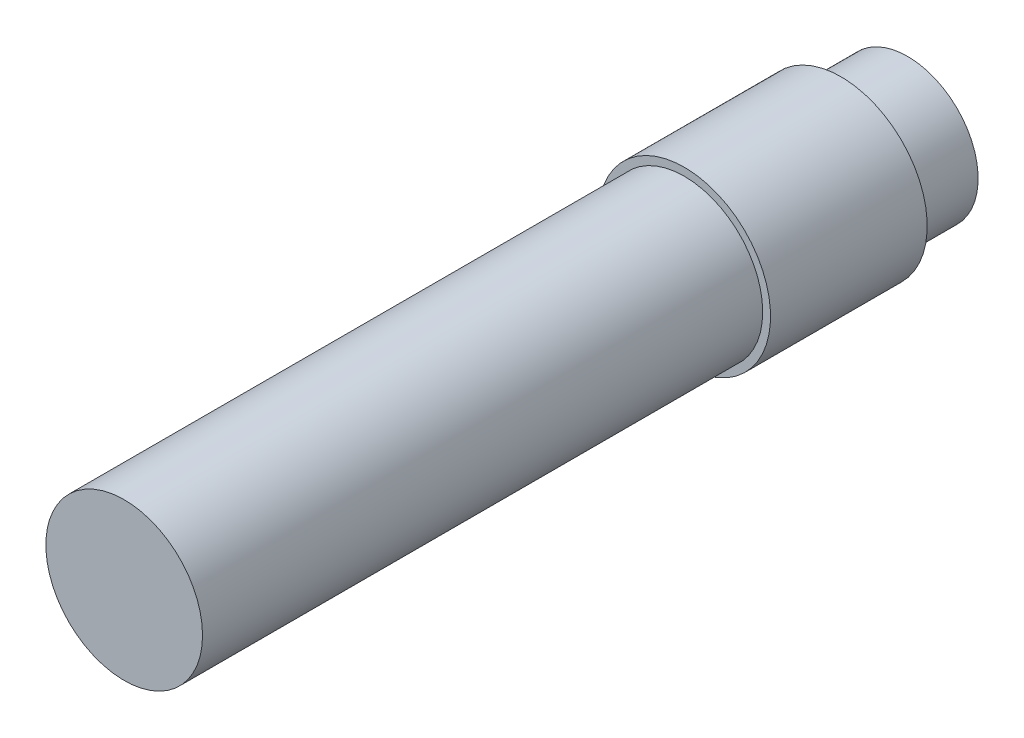
from build123d import *

# Parameters (mm, degrees)
SKETCH_1_R          = 11
EXTRUDE_1_DEPTH     = 100
SKETCH_2_R          = 11
SKETCH_2_R_2        = 9
CUT_EXTRUDE_1_DEPTH = 8.5
SKETCH_3_R          = 11
SKETCH_3_R_2        = 10
CUT_EXTRUDE_2_DEPTH = 71.5


with BuildPart() as part:
    # 草圖1 → 填料-伸長1 (new body)
    with BuildSketch(Plane.XY):
        Circle(SKETCH_1_R)
    extrude(amount=EXTRUDE_1_DEPTH)

    # 草圖2 → 除料-伸長1 (cut)
    with BuildSketch(Plane(origin=(0, 0, 0), x_dir=(-1, 0, 0), z_dir=(0, 0, -1))):
        Circle(SKETCH_2_R)
        Circle(SKETCH_2_R_2, mode=Mode.SUBTRACT)
    extrude(amount=-CUT_EXTRUDE_1_DEPTH, mode=Mode.SUBTRACT)

    # 草圖3 → 除料-伸長2 (cut)
    with BuildSketch(Plane.XY.offset(100)):
        Circle(SKETCH_3_R)
        Circle(SKETCH_3_R_2, mode=Mode.SUBTRACT)
    extrude(amount=-CUT_EXTRUDE_2_DEPTH, mode=Mode.SUBTRACT)


solid = part.part
